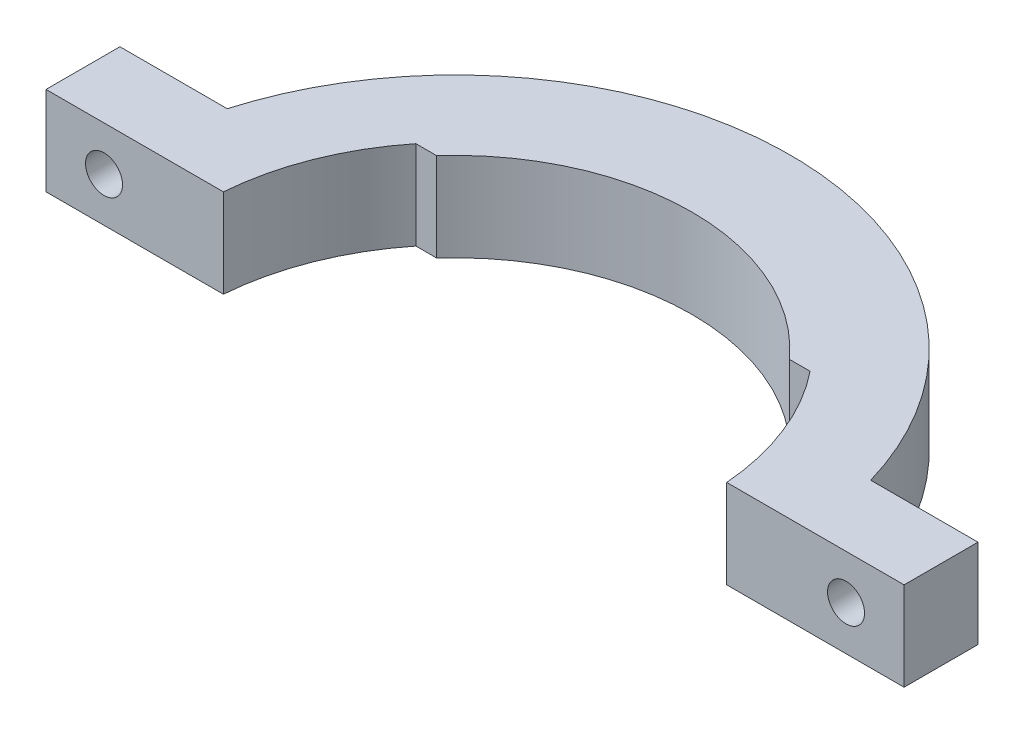
from build123d import *

# Parameters (mm, degrees)
SALIENTE_EXTRUIR1_DEPTH = 9
CROQUIS2_R              = 1.875
CORTAR_EXTRUIR1_DEPTH   = 51.759082577
CROQUIS2_3_R            = 3.5
CROQUIS2_3_R_2          = 1.875
CORTAR_EXTRUIR2_DEPTH   = 2.8


with BuildPart() as part:
    # Croquis1 → Saliente-Extruir1 (new body)
    with BuildSketch(Plane(origin=(0, 0, 0), x_dir=(1, 0, 0), z_dir=(0, 1, 0))):
        with BuildLine():
            Line((17.88854382, 16), (20, 16))
            ThreePointArc((20, 16), (23.818961075, 9.415789574), (25.53429067, 2))
            Line((25.53429067, 2), (43.53429067, 2))
            Line((43.53429067, 2), (43.53429067, 9.5))
            Line((43.53429067, 9.5), (32.645826686, 9.5))
            ThreePointArc((32.645826686, 9.5), (0, 34), (-32.645826686, 9.5))
            Line((-32.645826686, 9.5), (-43.53429067, 9.5))
            Line((-43.53429067, 9.5), (-43.53429067, 2))
            Line((-43.53429067, 2), (-25.53429067, 2))
            ThreePointArc((-25.53429067, 2), (-23.818961075, 9.415789574), (-20, 16))
            Line((-20, 16), (-17.88854382, 16))
            ThreePointArc((-17.88854382, 16), (0, 24), (17.88854382, 16))
        make_face()
    extrude(amount=SALIENTE_EXTRUIR1_DEPTH)

    # Croquis2 → Cortar-Extruir1 (cut, through all)
    with BuildSketch(Plane(origin=(0, 0, -9.5), x_dir=(-1, 0, 0), z_dir=(0, 0, -1))):
        with Locations((-37.645, 4.5)):
            Circle(CROQUIS2_R)
        with Locations((37.645, 4.5)):
            Circle(CROQUIS2_R)
    extrude(amount=-CORTAR_EXTRUIR1_DEPTH, mode=Mode.SUBTRACT)

    # Croquis2_3 → Cortar-Extruir2 (cut)
    # profile 1 of 2: a face of its own
    with BuildSketch(Plane(origin=(0, 0, -9.5), x_dir=(-1, 0, 0), z_dir=(0, 0, -1))):
        with Locations((-37.645, 4.5)):
            Circle(CROQUIS2_3_R)
        with Locations((-37.645, 4.5)):
            Circle(CROQUIS2_3_R_2, mode=Mode.SUBTRACT)
    # profile 2 of 2: a face of its own
    with BuildSketch(Plane(origin=(0, 0, -9.5), x_dir=(-1, 0, 0), z_dir=(0, 0, -1))):
        with Locations((37.645, 4.5)):
            Circle(CROQUIS2_3_R)
        with Locations((37.645, 4.5)):
            Circle(CROQUIS2_3_R_2, mode=Mode.SUBTRACT)
    extrude(amount=-CORTAR_EXTRUIR2_DEPTH, mode=Mode.SUBTRACT)


solid = part.part
